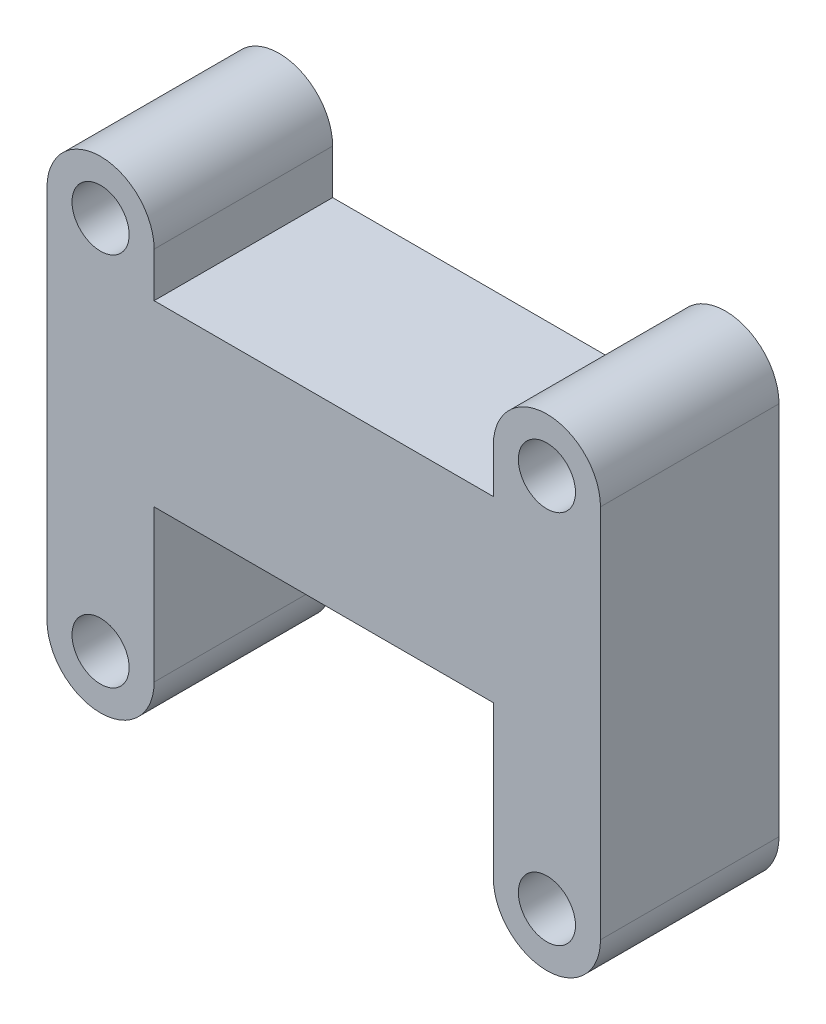
from build123d import *

# Parameters (mm, degrees)
SKETCH1_R           = 1.6
SKETCH1_W           = 19
SKETCH1_H           = 10
BOSS_EXTRUDE1_DEPTH = 10


with BuildPart() as part:
    # Sketch1 → Boss-Extrude1 (new body)
    with BuildSketch(Plane.XY):
        with BuildLine():
            Line((3, 0), (3, 21))
            ThreePointArc((3, 21), (0, 24), (-3, 21))
            Line((-3, 21), (-3, 0))
            ThreePointArc((-3, 0), (0, -3), (3, 0))
        make_face()
        Circle(SKETCH1_R, mode=Mode.SUBTRACT)
        with Locations((0, 21)):
            Circle(SKETCH1_R, mode=Mode.SUBTRACT)
        with Locations((12.5, 13.5)):
            Rectangle(SKETCH1_W, SKETCH1_H)
        with BuildLine():
            Line((22, 18.5), (22, 8.5))
            Line((22, 8.5), (22, 0))
            ThreePointArc((22, 0), (25, -3), (28, 0))
            Line((28, 0), (28, 21))
            ThreePointArc((28, 21), (25, 24), (22, 21))
            Line((22, 21), (22, 18.5))
        make_face()
        with Locations((25, 0)):
            Circle(SKETCH1_R, mode=Mode.SUBTRACT)
        with Locations((25, 21)):
            Circle(SKETCH1_R, mode=Mode.SUBTRACT)
    extrude(amount=BOSS_EXTRUDE1_DEPTH)


solid = part.part
